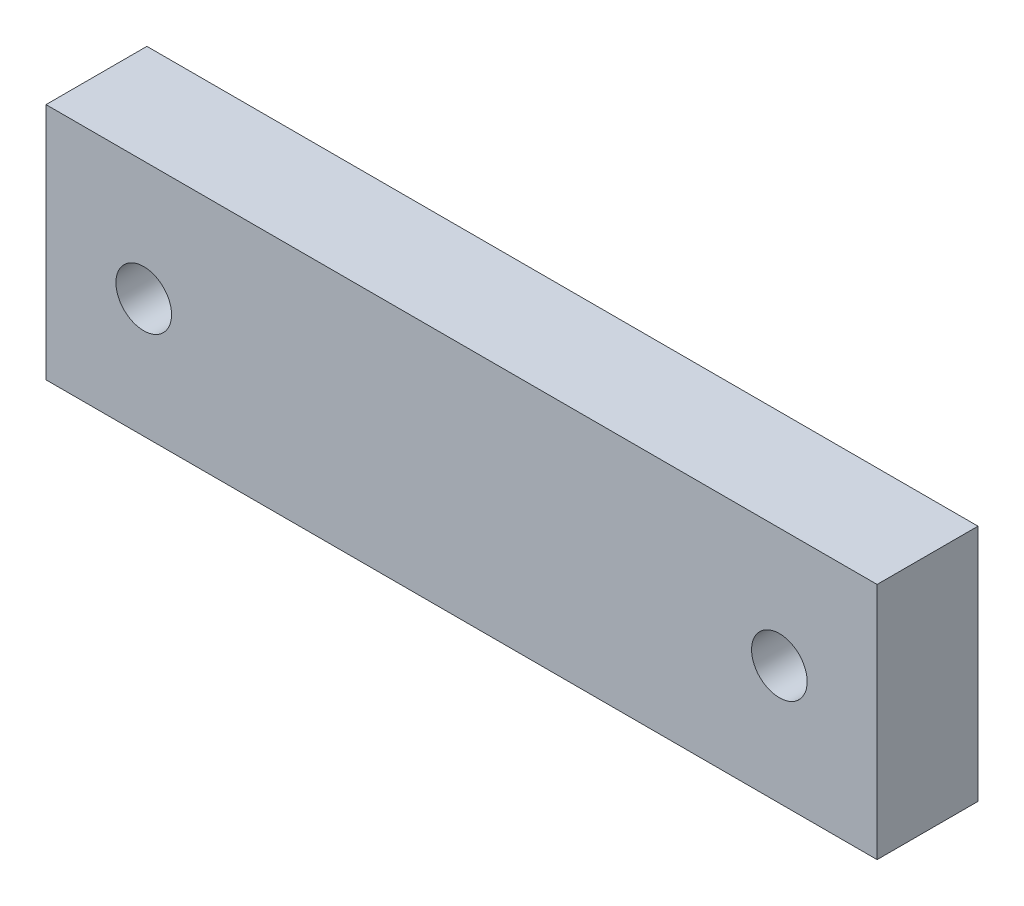
from build123d import *

# Parameters (mm, degrees)
SKETCH1_W           = 52.3
SKETCH1_H           = 15
SKETCH1_R           = 1.75
BOSS_EXTRUDE1_DEPTH = 6.35


with BuildPart() as part:
    # Sketch1 → Boss-Extrude1 (new body)
    with BuildSketch(Plane.XY):
        with Locations((26.15, 7.5)):
            Rectangle(SKETCH1_W, SKETCH1_H)
        with Locations((6.15, 7.5)):
            Circle(SKETCH1_R, mode=Mode.SUBTRACT)
        with Locations((46.15, 7.5)):
            Circle(SKETCH1_R, mode=Mode.SUBTRACT)
    extrude(amount=BOSS_EXTRUDE1_DEPTH)


solid = part.part
